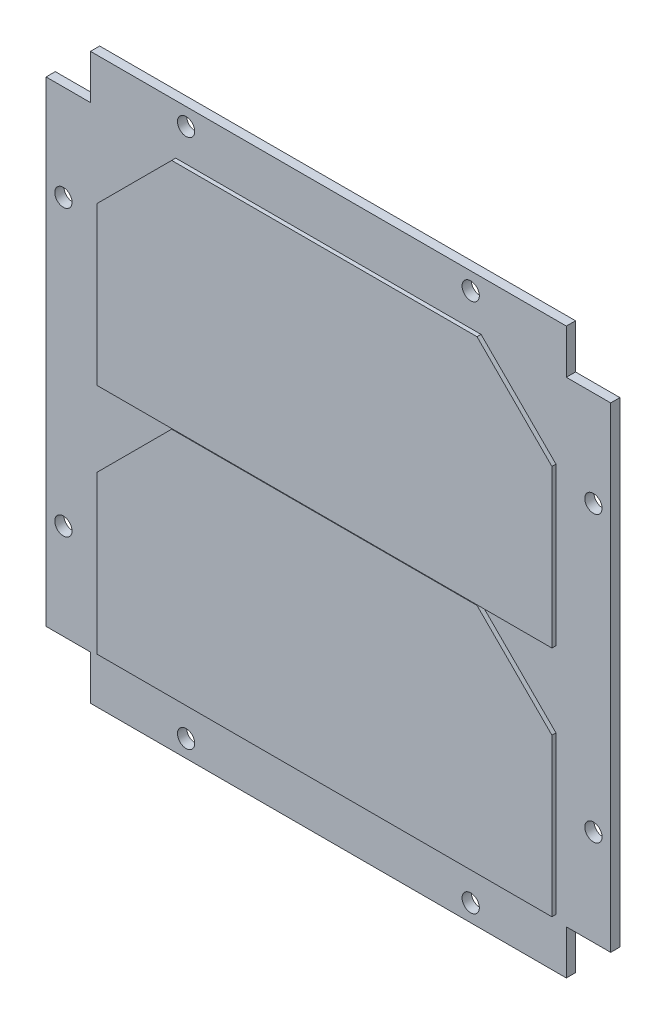
from build123d import *

# Parameters (mm, degrees)
SKETCH1_R           = 1.5
BOSS_EXTRUDE1_DEPTH = 1.6
BOSS_EXTRUDE2_DEPTH = 2.3


with BuildPart() as part:
    # Sketch1 → Boss-Extrude1 (new body)
    with BuildSketch(Plane.XY):
        Polygon((-65.182649766, 43.872204631), (-65.182649766, 36.172204631), (-72.882649766, 36.172204631), (-72.882649766, -46.427795369), (-65.182649766, -46.427795369), (-65.182649766, -54.127795369), (17.417350234, -54.127795369), (17.417350234, -46.427795369), (25.117350234, -46.427795369), (25.117350234, 36.172204631), (17.417350234, 36.172204631), (17.417350234, 43.872204631), align=None)
        with Locations((-69.882649766, 19.572204631)):
            Circle(SKETCH1_R, mode=Mode.SUBTRACT)
        with Locations((-69.882649766, -29.827795369)):
            Circle(SKETCH1_R, mode=Mode.SUBTRACT)
        with Locations((-48.582649766, -51.127795369)):
            Circle(SKETCH1_R, mode=Mode.SUBTRACT)
        with Locations((0.817350234, -51.127795369)):
            Circle(SKETCH1_R, mode=Mode.SUBTRACT)
        with Locations((22.117350234, -29.827795369)):
            Circle(SKETCH1_R, mode=Mode.SUBTRACT)
        with Locations((22.117350234, 19.572204631)):
            Circle(SKETCH1_R, mode=Mode.SUBTRACT)
        with Locations((0.817350234, 40.872204631)):
            Circle(SKETCH1_R, mode=Mode.SUBTRACT)
        with Locations((-48.582649766, 40.872204631)):
            Circle(SKETCH1_R, mode=Mode.SUBTRACT)
        Polygon((-63.382649766, 22.222204631), (-50.382649766, 35.222204631), (2.617350234, 35.222204631), (15.617350234, 22.222204631), (15.617350234, -5.077795369), (-63.382649766, -5.077795369), align=None, mode=Mode.SUBTRACT)
        Polygon((-63.382649766, -18.177795369), (-50.382649766, -5.177795369), (2.617350234, -5.177795369), (15.617350234, -18.177795369), (15.617350234, -45.477795369), (-63.382649766, -45.477795369), align=None, mode=Mode.SUBTRACT)
    extrude(amount=BOSS_EXTRUDE1_DEPTH)

    # Sketch1_3 → Boss-Extrude2 (add)
    with BuildSketch(Plane.XY):
        Polygon((-50.382649766, 35.222204631), (-63.382649766, 22.222204631), (-63.382649766, -5.077795369), (15.617350234, -5.077795369), (15.617350234, 22.222204631), (2.617350234, 35.222204631), align=None)
        Polygon((-50.382649766, -5.177795369), (-63.382649766, -18.177795369), (-63.382649766, -45.477795369), (15.617350234, -45.477795369), (15.617350234, -18.177795369), (2.617350234, -5.177795369), align=None)
    extrude(amount=BOSS_EXTRUDE2_DEPTH)


solid = part.part
